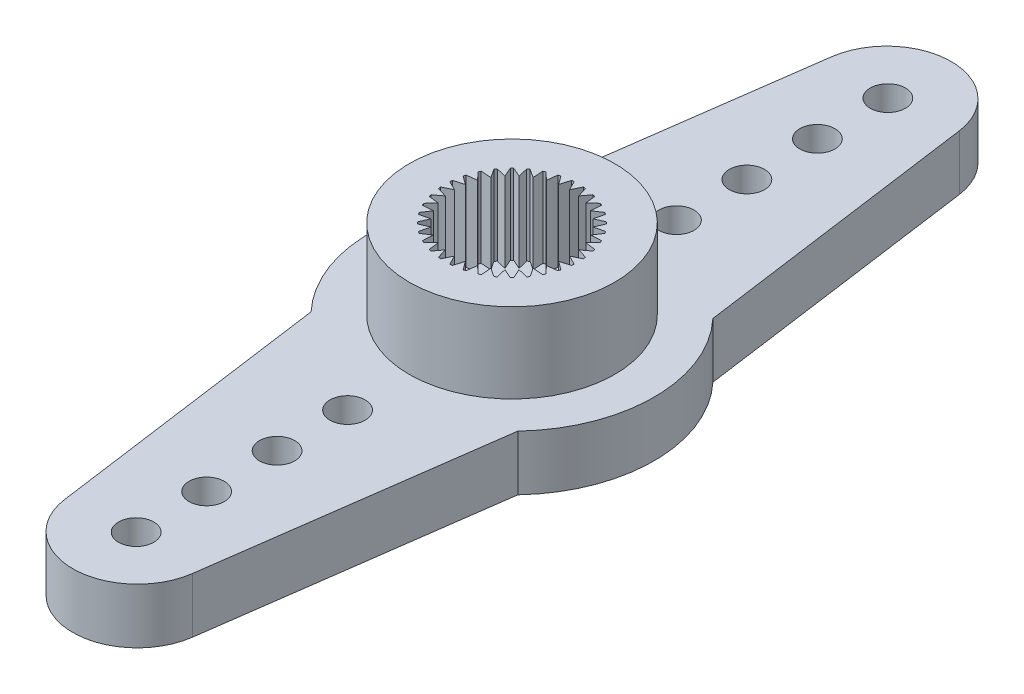
from build123d import *

# Parameters (mm, degrees)
BOSS_EXTRUDE1_DEPTH                                = 2.35
SKETCH2_R                                          = 4.375
BOSS_EXTRUDE2_DEPTH                                = 3.4
CUT_EXTRUDE1_DEPTH                                 = 3.4
F_8_8_8_8_DIAMETER_HOLE1_D                         = 8.8
F_8_8_8_8_DIAMETER_HOLE1_DEPTH                     = 0.3
SKETCH6_W                                          = 3.25
SKETCH6_H                                          = 0.3
F_1_5_1_5_DIAMETER_HOLE1_D                         = 1.5
F_1_5_1_5_DIAMETER_HOLE1_DEPTH                     = 2.35
CBORE_FOR_M2_5_HEX_HEAD_MACHINE_SCREW1_D           = 3
CBORE_FOR_M2_5_HEX_HEAD_MACHINE_SCREW1_DEPTH       = 5.75
CBORE_FOR_M2_5_HEX_HEAD_MACHINE_SCREW1_CBORE_D     = 5.5
CBORE_FOR_M2_5_HEX_HEAD_MACHINE_SCREW1_CBORE_DEPTH = 0.3


with BuildPart() as part:
    # Sketch1 → Boss-Extrude1 (new body)
    with BuildSketch(Plane(origin=(0, 2.35, 0), x_dir=(1, 0, 0), z_dir=(0, 1, 0))):
        with BuildLine():
            Line((2.724307673, -16.32503027), (4.4, -4.152408939))
            ThreePointArc((4.4, -4.152408939), (6.05, 0), (4.4, 4.152408939))
            Line((4.4, 4.152408939), (2.724307673, 16.32503027))
            ThreePointArc((2.724307673, 16.32503027), (0, 18.7), (-2.724307673, 16.32503027))
            Line((-2.724307673, 16.32503027), (-4.4, 4.152408939))
            ThreePointArc((-4.4, 4.152408939), (-6.05, 0), (-4.4, -4.152408939))
            Line((-4.4, -4.152408939), (-2.724307673, -16.32503027))
            ThreePointArc((-2.724307673, -16.32503027), (0, -18.7), (2.724307673, -16.32503027))
        make_face()
    extrude(amount=-BOSS_EXTRUDE1_DEPTH)

    # Sketch2 → Boss-Extrude2 (add)
    with BuildSketch(Plane(origin=(0, 2.35, 0), x_dir=(-1, 0, 0), z_dir=(0, 1, 0))):
        Circle(SKETCH2_R)
    extrude(amount=BOSS_EXTRUDE2_DEPTH)

    # Sketch3 → Cut-Extrude1 (cut)
    with BuildSketch(Plane(origin=(0, 5.75, 0), x_dir=(-1, 0, 0), z_dir=(0, 1, 0))):
        with BuildLine():
            Line((0.687336745, 2.765875666), (0.425438035, 2.412778995))
            Line((0.425438035, 2.412778995), (0.300099924, 2.834155965))
            ThreePointArc((0.300099924, 2.834155965), (0.248393867, 2.83915489), (0.196605286, 2.843210573))
            Line((0.196605286, 2.843210573), (0, 2.45))
            Line((0, 2.45), (-0.196605286, 2.843210573))
            ThreePointArc((-0.196605286, 2.843210573), (-0.248393867, 2.83915489), (-0.300099924, 2.834155965))
            Line((-0.300099924, 2.834155965), (-0.425438035, 2.412778995))
            Line((-0.425438035, 2.412778995), (-0.687336745, 2.765875666))
            ThreePointArc((-0.687336745, 2.765875666), (-0.737634279, 2.752888605), (-0.787686751, 2.738986963))
            Line((-0.787686751, 2.738986963), (-0.837949351, 2.302246921))
            Line((-0.837949351, 2.302246921), (-1.157183824, 2.604501026))
            ThreePointArc((-1.157183824, 2.604501026), (-1.204462046, 2.582977193), (-1.251340114, 2.560595228))
            Line((-1.251340114, 2.560595228), (-1.225, 2.121762239))
            Line((-1.225, 2.121762239), (-1.591870459, 2.363989941))
            ThreePointArc((-1.591870459, 2.363989941), (-1.634692844, 2.334583326), (-1.676972141, 2.304401102))
            Line((-1.676972141, 2.304401102), (-1.574829644, 1.876808886))
            Line((-1.574829644, 1.876808886), (-1.978188915, 2.051650218))
            ThreePointArc((-1.978188915, 2.051650218), (-2.015254326, 2.015254326), (-2.051650218, 1.978188915))
            Line((-2.051650218, 1.978188915), (-1.876808886, 1.574829644))
            Line((-1.876808886, 1.574829644), (-2.304401102, 1.676972141))
            ThreePointArc((-2.304401102, 1.676972141), (-2.334583326, 1.634692844), (-2.363989941, 1.591870459))
            Line((-2.363989941, 1.591870459), (-2.121762239, 1.225))
            Line((-2.121762239, 1.225), (-2.560595228, 1.251340114))
            ThreePointArc((-2.560595228, 1.251340114), (-2.582977193, 1.204462046), (-2.604501026, 1.157183824))
            Line((-2.604501026, 1.157183824), (-2.302246921, 0.837949351))
            Line((-2.302246921, 0.837949351), (-2.738986963, 0.787686751))
            ThreePointArc((-2.738986963, 0.787686751), (-2.752888605, 0.737634279), (-2.765875666, 0.687336745))
            Line((-2.765875666, 0.687336745), (-2.412778995, 0.425438035))
            Line((-2.412778995, 0.425438035), (-2.834155965, 0.300099924))
            ThreePointArc((-2.834155965, 0.300099924), (-2.83915489, 0.248393867), (-2.843210573, 0.196605286))
            Line((-2.843210573, 0.196605286), (-2.45, 0))
            Line((-2.45, 0), (-2.843210573, -0.196605286))
            ThreePointArc((-2.843210573, -0.196605286), (-2.83915489, -0.248393867), (-2.834155965, -0.300099924))
            Line((-2.834155965, -0.300099924), (-2.412778995, -0.425438035))
            Line((-2.412778995, -0.425438035), (-2.765875666, -0.687336745))
            ThreePointArc((-2.765875666, -0.687336745), (-2.752888605, -0.737634279), (-2.738986963, -0.787686751))
            Line((-2.738986963, -0.787686751), (-2.302246921, -0.837949351))
            Line((-2.302246921, -0.837949351), (-2.604501026, -1.157183824))
            ThreePointArc((-2.604501026, -1.157183824), (-2.582977193, -1.204462046), (-2.560595228, -1.251340114))
            Line((-2.560595228, -1.251340114), (-2.121762239, -1.225))
            Line((-2.121762239, -1.225), (-2.363989941, -1.591870459))
            ThreePointArc((-2.363989941, -1.591870459), (-2.334583326, -1.634692844), (-2.304401102, -1.676972141))
            Line((-2.304401102, -1.676972141), (-1.876808886, -1.574829644))
            Line((-1.876808886, -1.574829644), (-2.051650218, -1.978188915))
            ThreePointArc((-2.051650218, -1.978188915), (-2.015254326, -2.015254326), (-1.978188915, -2.051650218))
            Line((-1.978188915, -2.051650218), (-1.574829644, -1.876808886))
            Line((-1.574829644, -1.876808886), (-1.676972141, -2.304401102))
            ThreePointArc((-1.676972141, -2.304401102), (-1.634692844, -2.334583326), (-1.591870459, -2.363989941))
            Line((-1.591870459, -2.363989941), (-1.225, -2.121762239))
            Line((-1.225, -2.121762239), (-1.251340114, -2.560595228))
            ThreePointArc((-1.251340114, -2.560595228), (-1.204462046, -2.582977193), (-1.157183824, -2.604501026))
            Line((-1.157183824, -2.604501026), (-0.837949351, -2.302246921))
            Line((-0.837949351, -2.302246921), (-0.787686751, -2.738986963))
            ThreePointArc((-0.787686751, -2.738986963), (-0.737634279, -2.752888605), (-0.687336745, -2.765875666))
            Line((-0.687336745, -2.765875666), (-0.425438035, -2.412778995))
            Line((-0.425438035, -2.412778995), (-0.300099924, -2.834155965))
            ThreePointArc((-0.300099924, -2.834155965), (-0.248393867, -2.83915489), (-0.196605286, -2.843210573))
            Line((-0.196605286, -2.843210573), (0, -2.45))
            Line((0, -2.45), (0.196605286, -2.843210573))
            ThreePointArc((0.196605286, -2.843210573), (0.248393867, -2.83915489), (0.300099924, -2.834155965))
            Line((0.300099924, -2.834155965), (0.425438035, -2.412778995))
            Line((0.425438035, -2.412778995), (0.687336745, -2.765875666))
            ThreePointArc((0.687336745, -2.765875666), (0.737634279, -2.752888605), (0.787686751, -2.738986963))
            Line((0.787686751, -2.738986963), (0.837949351, -2.302246921))
            Line((0.837949351, -2.302246921), (1.157183824, -2.604501026))
            ThreePointArc((1.157183824, -2.604501026), (1.204462046, -2.582977193), (1.251340114, -2.560595228))
            Line((1.251340114, -2.560595228), (1.225, -2.121762239))
            Line((1.225, -2.121762239), (1.591870459, -2.363989941))
            ThreePointArc((1.591870459, -2.363989941), (1.634692844, -2.334583326), (1.676972141, -2.304401102))
            Line((1.676972141, -2.304401102), (1.574829644, -1.876808886))
            Line((1.574829644, -1.876808886), (1.978188915, -2.051650218))
            ThreePointArc((1.978188915, -2.051650218), (2.015254326, -2.015254326), (2.051650218, -1.978188915))
            Line((2.051650218, -1.978188915), (1.876808886, -1.574829644))
            Line((1.876808886, -1.574829644), (2.304401102, -1.676972141))
            ThreePointArc((2.304401102, -1.676972141), (2.334583326, -1.634692844), (2.363989941, -1.591870459))
            Line((2.363989941, -1.591870459), (2.121762239, -1.225))
            Line((2.121762239, -1.225), (2.560595228, -1.251340114))
            ThreePointArc((2.560595228, -1.251340114), (2.582977193, -1.204462046), (2.604501026, -1.157183824))
            Line((2.604501026, -1.157183824), (2.302246921, -0.837949351))
            Line((2.302246921, -0.837949351), (2.738986963, -0.787686751))
            ThreePointArc((2.738986963, -0.787686751), (2.752888605, -0.737634279), (2.765875666, -0.687336745))
            Line((2.765875666, -0.687336745), (2.412778995, -0.425438035))
            Line((2.412778995, -0.425438035), (2.834155965, -0.300099924))
            ThreePointArc((2.834155965, -0.300099924), (2.83915489, -0.248393867), (2.843210573, -0.196605286))
            Line((2.843210573, -0.196605286), (2.45, 0))
            Line((2.45, 0), (2.843210573, 0.196605286))
            ThreePointArc((2.843210573, 0.196605286), (2.83915489, 0.248393867), (2.834155965, 0.300099924))
            Line((2.834155965, 0.300099924), (2.412778995, 0.425438035))
            Line((2.412778995, 0.425438035), (2.765875666, 0.687336745))
            ThreePointArc((2.765875666, 0.687336745), (2.752888605, 0.737634279), (2.738986963, 0.787686751))
            Line((2.738986963, 0.787686751), (2.302246921, 0.837949351))
            Line((2.302246921, 0.837949351), (2.604501026, 1.157183824))
            ThreePointArc((2.604501026, 1.157183824), (2.582977193, 1.204462046), (2.560595228, 1.251340114))
            Line((2.560595228, 1.251340114), (2.121762239, 1.225))
            Line((2.121762239, 1.225), (2.363989941, 1.591870459))
            ThreePointArc((2.363989941, 1.591870459), (2.334583326, 1.634692844), (2.304401102, 1.676972141))
            Line((2.304401102, 1.676972141), (1.876808886, 1.574829644))
            Line((1.876808886, 1.574829644), (2.051650218, 1.978188915))
            ThreePointArc((2.051650218, 1.978188915), (2.015254326, 2.015254326), (1.978188915, 2.051650218))
            Line((1.978188915, 2.051650218), (1.574829644, 1.876808886))
            Line((1.574829644, 1.876808886), (1.676972141, 2.304401102))
            ThreePointArc((1.676972141, 2.304401102), (1.634692844, 2.334583326), (1.591870459, 2.363989941))
            Line((1.591870459, 2.363989941), (1.225, 2.121762239))
            Line((1.225, 2.121762239), (1.251340114, 2.560595228))
            ThreePointArc((1.251340114, 2.560595228), (1.204462046, 2.582977193), (1.157183824, 2.604501026))
            Line((1.157183824, 2.604501026), (0.837949351, 2.302246921))
            Line((0.837949351, 2.302246921), (0.787686751, 2.738986963))
            ThreePointArc((0.787686751, 2.738986963), (0.737634279, 2.752888605), (0.687336745, 2.765875666))
        make_face()
    extrude(amount=-CUT_EXTRUDE1_DEPTH, mode=Mode.SUBTRACT)

    # Ø8.8 (8.8) Diameter Hole1
    with Locations(Plane(origin=(0, 0, 0), x_dir=(-1, 0, 0), z_dir=(0, -1, 0))):
        with Locations((0, 0)):
            Hole(F_8_8_8_8_DIAMETER_HOLE1_D / 2, depth=F_8_8_8_8_DIAMETER_HOLE1_DEPTH)

    # Sketch6 → Revolve1 (revolve)
    with BuildSketch(Plane.XY):
        with Locations((1.625, 0.15)):
            Rectangle(SKETCH6_W, SKETCH6_H)
    revolve(axis=Axis((0, 0.3, 0), (0, -1, 0)))

    # Ø1.5 (1.5) Diameter Hole1
    with Locations(Plane(origin=(0, 2.35, 0), x_dir=(1, 0, 0), z_dir=(0, 1, 0))):
        with Locations((0, -7), (0, 16), (0, -10), (0, -13), (0, -16), (0, 13), (0, 10), (0, 7)):
            Hole(F_1_5_1_5_DIAMETER_HOLE1_D / 2, depth=F_1_5_1_5_DIAMETER_HOLE1_DEPTH)

    # CBORE for M2.5 Hex Head Machine Screw1
    with Locations(Plane(origin=(0, 0, 0), x_dir=(-1, 0, 0), z_dir=(0, -1, 0))):
        with Locations((0, 0)):
            CounterBoreHole(CBORE_FOR_M2_5_HEX_HEAD_MACHINE_SCREW1_D / 2, CBORE_FOR_M2_5_HEX_HEAD_MACHINE_SCREW1_CBORE_D / 2, CBORE_FOR_M2_5_HEX_HEAD_MACHINE_SCREW1_CBORE_DEPTH, depth=CBORE_FOR_M2_5_HEX_HEAD_MACHINE_SCREW1_DEPTH)


solid = part.part
